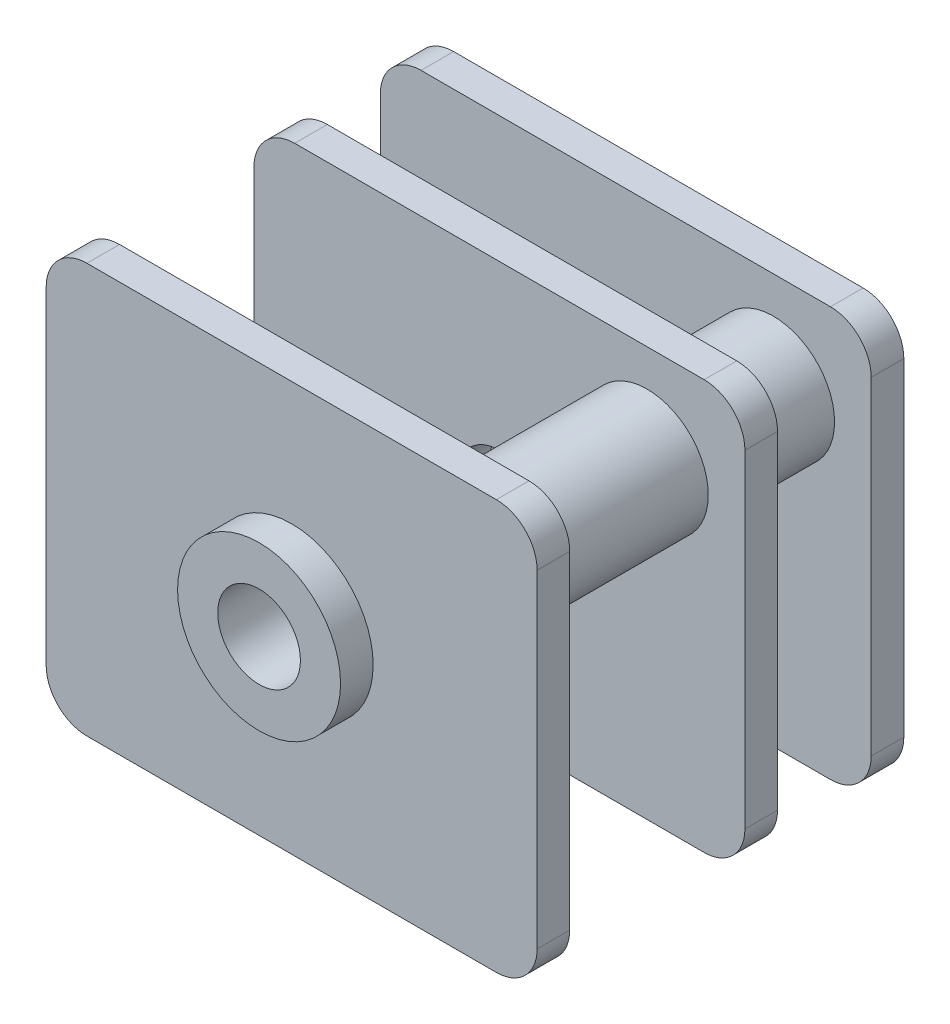
from build123d import *

# Parameters (mm, degrees)
SKICA5_W                 = 12.05
SKICA5_H                 = 10.05
P_IDAT_VYSUNUT_M5_DEPTH  = 0.8
ZAOBLIT2_R               = 1
SKICA6_R                 = 1.5
P_IDAT_VYSUNUT_M6_DEPTH  = 7.4
LINPOLE1_COUNT           = 2
LINPOLE1_PITCH           = 3.1
ZAOBLIT2_OF_LINPOLE1_R   = 1
LINPOLE2_COUNT           = 2
LINPOLE2_PITCH           = 8.2
ZAOBLIT2_OF_LINPOLE2_R   = 1
SKICA7_R                 = 2
SKICA7_R_2               = 1.015
P_IDAT_VYSUNUT_M7_DEPTH  = 0.8
SKICA9_R                 = 1.015
ODEBRAT_VYSUNUT_M2_DEPTH = 10.8


with BuildPart() as part:
    # Skica5 → Přidat vysunutím5 (new body)
    with BuildSketch(Plane.XY):
        Rectangle(SKICA5_W, SKICA5_H)
    p_idat_vysunut_m5 = extrude(amount=P_IDAT_VYSUNUT_M5_DEPTH)

    # Zaoblit2
    zaoblit2_edges = [part.edges().sort_by_distance(p)[0] for p in [
        (6.025, -5.025, 0.4),
        (-6.025, -5.025, 0.4),
        (-6.025, 5.025, 0.4),
        (6.025, 5.025, 0.4),
    ]]
    fillet(zaoblit2_edges, radius=ZAOBLIT2_R)

    # Skica6 → Přidat vysunutím6 (add)
    with BuildSketch(Plane.XY.offset(0.8)):
        with Locations((3.625, 2.625)):
            Circle(SKICA6_R)
        with Locations((-3.625, -2.625)):
            Circle(SKICA6_R)
    extrude(amount=P_IDAT_VYSUNUT_M6_DEPTH)

    # LinPole1: Přidat vysunutím5 ×2
    with Locations(*[(0, 0, i * LINPOLE1_PITCH) for i in range(1, LINPOLE1_COUNT)]):
        add(p_idat_vysunut_m5)

    # Zaoblit2 of LinPole1
    zaoblit2_of_linpole1_edges = [part.edges().sort_by_distance(p)[0] for p in [
        (6.025, -5.025, 3.5),
        (-6.025, -5.025, 3.5),
        (-6.025, 5.025, 3.5),
        (6.025, 5.025, 3.5),
    ]]
    fillet(zaoblit2_of_linpole1_edges, radius=ZAOBLIT2_OF_LINPOLE1_R)

    # LinPole2: Přidat vysunutím5 ×2
    with Locations(*[(0, 0, i * LINPOLE2_PITCH) for i in range(1, LINPOLE2_COUNT)]):
        add(p_idat_vysunut_m5)

    # Zaoblit2 of LinPole2
    zaoblit2_of_linpole2_edges = [part.edges().sort_by_distance(p)[0] for p in [
        (6.025, -5.025, 8.6),
        (-6.025, -5.025, 8.6),
        (-6.025, 5.025, 8.6),
        (6.025, 5.025, 8.6),
    ]]
    fillet(zaoblit2_of_linpole2_edges, radius=ZAOBLIT2_OF_LINPOLE2_R)

    # Skica7 → Přidat vysunutím7 (add)
    with BuildSketch(Plane.XY.offset(9)):
        Circle(SKICA7_R)
        Circle(SKICA7_R_2, mode=Mode.SUBTRACT)
    extrude(amount=P_IDAT_VYSUNUT_M7_DEPTH)

    # Skica9 → Odebrat vysunutím2 (cut, through all)
    with BuildSketch(Plane.XY):
        Circle(SKICA9_R)
    extrude(amount=ODEBRAT_VYSUNUT_M2_DEPTH, mode=Mode.SUBTRACT)


solid = part.part
